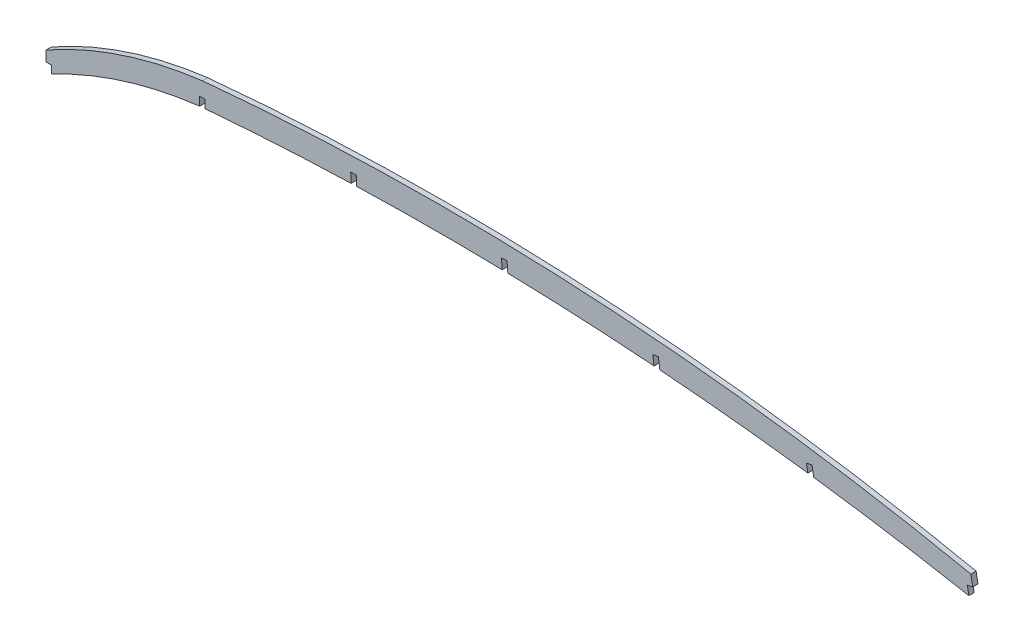
from build123d import *

# Parameters (mm, degrees)
BOSS_EXTRUDE1_DEPTH = 3.175
SKETCH2_W           = 3.3528
SKETCH2_H           = 6.477
SKETCH2_W_2         = 3.3782
SKETCH2_H_2         = 12.7
CUT_EXTRUDE1_DEPTH  = 4.175


with BuildPart() as part:
    # Sketch1 → Boss-Extrude1 (new body)
    with BuildSketch(Plane.XY):
        with BuildLine():
            Line((555.638244479, 111.822940833), (557.916984218, 99.326538403))
            ThreePointArc((557.916984218, 99.326538403), (326.784483289, 127.411721364), (93.98, 123.794671649))
            ThreePointArc((93.98, 123.794671649), (45.52945751, 113.491169294), (0, 93.98))
            Line((0, 93.98), (0, 106.68))
            ThreePointArc((0, 106.68), (45.466310815, 126.795024577), (93.98, 137.668))
            ThreePointArc((93.98, 137.668), (325.782502236, 142.132503557), (555.638244479, 111.822940833))
        make_face()
    extrude(amount=BOSS_EXTRUDE1_DEPTH)

    # Sketch2 → Cut-Extrude1 (cut, through all)
    with BuildSketch(Plane.XY.offset(3.175)):
        with Locations((1.6764, 97.2185)):
            Rectangle(SKETCH2_W, SKETCH2_H)
        with Locations((93.98, 122.498746884)):
            Rectangle(SKETCH2_W_2, SKETCH2_H_2)
        Polygon((183.054551015, 134.687145422), (186.429805755, 134.828179757), (186.960010022, 122.139252165), (183.584755283, 121.99821783), align=None)
        Polygon((364.577933431, 130.603714492), (367.926681813, 131.048820676), (369.239873525, 121.16904642), (365.891125143, 120.723940236), align=None)
        Polygon((298.533171127, -116.284523632), (299.081273341, -122.651898671), (295.917971315, -122.924194999), (295.369869101, -116.55681996), align=None)
        Polygon((273.590830142, 135.268456112), (276.956583497, 135.558179406), (278.045768811, 122.904971301), (274.680015455, 122.615248007), align=None)
        Polygon((456.854976279, 120.249363717), (460.178373044, 120.855391093), (461.793693389, 111.99712722), (458.470296624, 111.391099845), align=None)
        Polygon((553.540722528, 105.060688054), (556.864119293, 105.666715431), (558.657365749, 95.832721624), (555.333968984, 95.226694247), align=None)
    extrude(amount=-CUT_EXTRUDE1_DEPTH, mode=Mode.SUBTRACT)


solid = part.part
